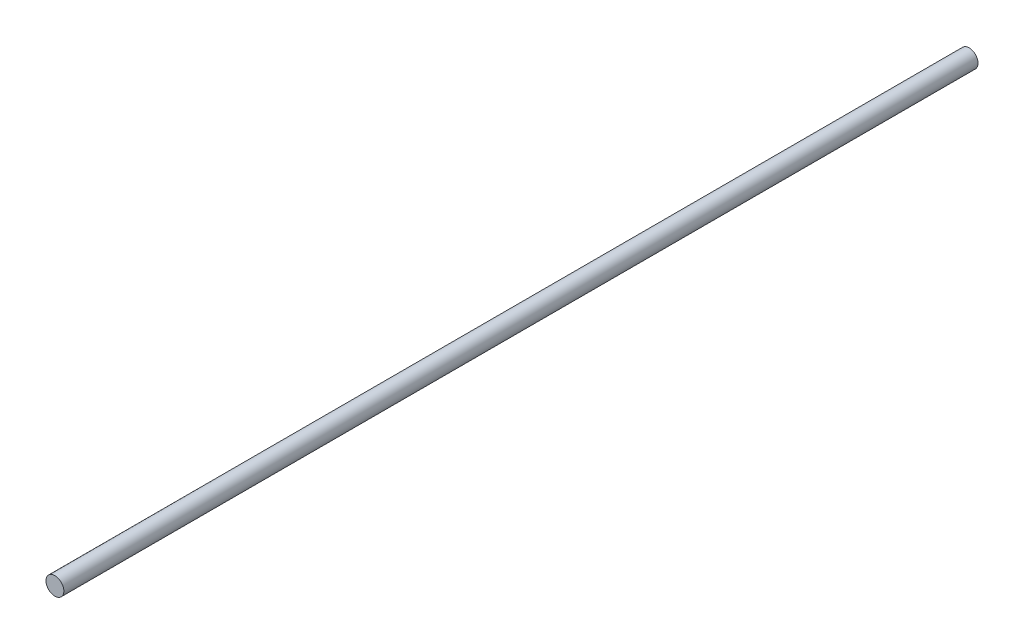
from build123d import *

# Parameters (mm, degrees)
SKETCH_1_R      = 4
EXTRUDE_1_DEPTH = 410


with BuildPart() as part:
    # 草图1 → 凸台-拉伸1 (new body)
    with BuildSketch(Plane.XY):
        Circle(SKETCH_1_R)
    extrude(amount=EXTRUDE_1_DEPTH)


solid = part.part
